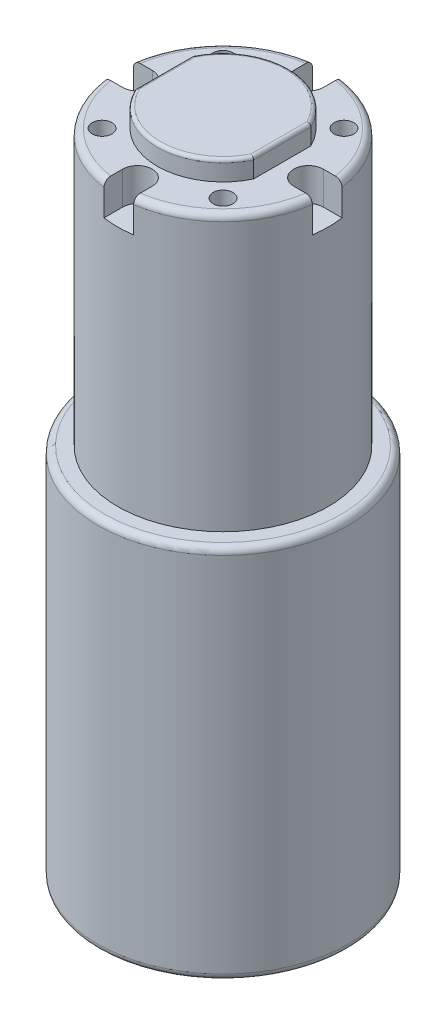
from build123d import *

# Parameters (mm, degrees)
BOSS_EXTRUDE3_DEPTH = 3
SKETCH7_R           = 16
BOSS_EXTRUDE4_DEPTH = 41.8
SKETCH8_R           = 19
BOSS_EXTRUDE5_DEPTH = 57.1
FILLET1_R           = 1
FILLET2_R           = 0.5
SKETCH9_R           = 1.5
CUT_EXTRUDE2_DEPTH  = 5
FILLET3_R           = 1


with BuildPart() as part:
    # Sketch5 → Boss-Extrude3 (new body)
    with BuildSketch(Plane(origin=(0, 0, 0), x_dir=(1, 0, 0), z_dir=(0, 1, 0))):
        with BuildLine():
            Line((-9, -4.358898944), (-9, 4.358898944))
            ThreePointArc((-9, 4.358898944), (0, 10), (9, 4.358898944))
            Line((9, 4.358898944), (9, -4.358898944))
            ThreePointArc((9, -4.358898944), (0, -10), (-9, -4.358898944))
        make_face()
    extrude(amount=-BOSS_EXTRUDE3_DEPTH)

    # Sketch7 → Boss-Extrude4 (add)
    with BuildSketch(Plane(origin=(0, -3, 0), x_dir=(-1, 0, 0), z_dir=(0, -1, 0))):
        Circle(SKETCH7_R)
    extrude(amount=BOSS_EXTRUDE4_DEPTH)

    # Sketch8 → Boss-Extrude5 (add)
    with BuildSketch(Plane(origin=(0, -44.8, 0), x_dir=(-1, 0, 0), z_dir=(0, -1, 0))):
        Circle(SKETCH8_R)
    extrude(amount=BOSS_EXTRUDE5_DEPTH)

    # Fillet1
    fillet1_edges = [part.edges().sort_by_distance(p)[0] for p in [
        (16, -3, 0),
        (19, -44.8, 0),
    ]]
    fillet(fillet1_edges, radius=FILLET1_R)

    # Fillet2
    fillet2_edges = [part.edges().sort_by_distance(p)[0] for p in [
        (9, 0, 0),
        (0, 0, 10),
        (-9, 0, 0),
        (0, 0, -10),
    ]]
    fillet(fillet2_edges, radius=FILLET2_R)

    # Sketch9 → Cut-Extrude2 (cut)
    with BuildSketch(Plane(origin=(0, -3, 0), x_dir=(-1, 0, 0), z_dir=(0, -1, 0))):
        with Locations((9.192388155, -9.192388155)):
            Circle(SKETCH9_R)
        with Locations((-9.192388155, -9.192388155)):
            Circle(SKETCH9_R)
        with Locations((-9.192388155, 9.192388155)):
            Circle(SKETCH9_R)
        with Locations((9.192388155, 9.192388155)):
            Circle(SKETCH9_R)
        with BuildLine():
            Line((-17.5, -2.25), (-17.5, 2.25))
            Line((-17.5, 2.25), (-13, 2.25))
            ThreePointArc((-13, 2.25), (-10.75, 0), (-13, -2.25))
            Line((-13, -2.25), (-17.5, -2.25))
        make_face()
        with BuildLine():
            Line((2.25, -17.5), (-2.25, -17.5))
            Line((-2.25, -17.5), (-2.25, -13))
            ThreePointArc((-2.25, -13), (0, -10.75), (2.25, -13))
            Line((2.25, -13), (2.25, -17.5))
        make_face()
        with BuildLine():
            Line((-2.25, 17.5), (2.25, 17.5))
            Line((2.25, 17.5), (2.25, 13))
            ThreePointArc((2.25, 13), (0, 10.75), (-2.25, 13))
            Line((-2.25, 13), (-2.25, 17.5))
        make_face()
        with BuildLine():
            Line((17.5, 2.25), (17.5, -2.25))
            Line((17.5, -2.25), (13, -2.25))
            ThreePointArc((13, -2.25), (10.75, 0), (13, 2.25))
            Line((13, 2.25), (17.5, 2.25))
        make_face()
    extrude(amount=CUT_EXTRUDE2_DEPTH, mode=Mode.SUBTRACT)

    # Fillet3
    fillet3_edges = [part.edges().sort_by_distance(p)[0] for p in [
        (19, -101.9, 0),
    ]]
    fillet(fillet3_edges, radius=FILLET3_R)


solid = part.part
